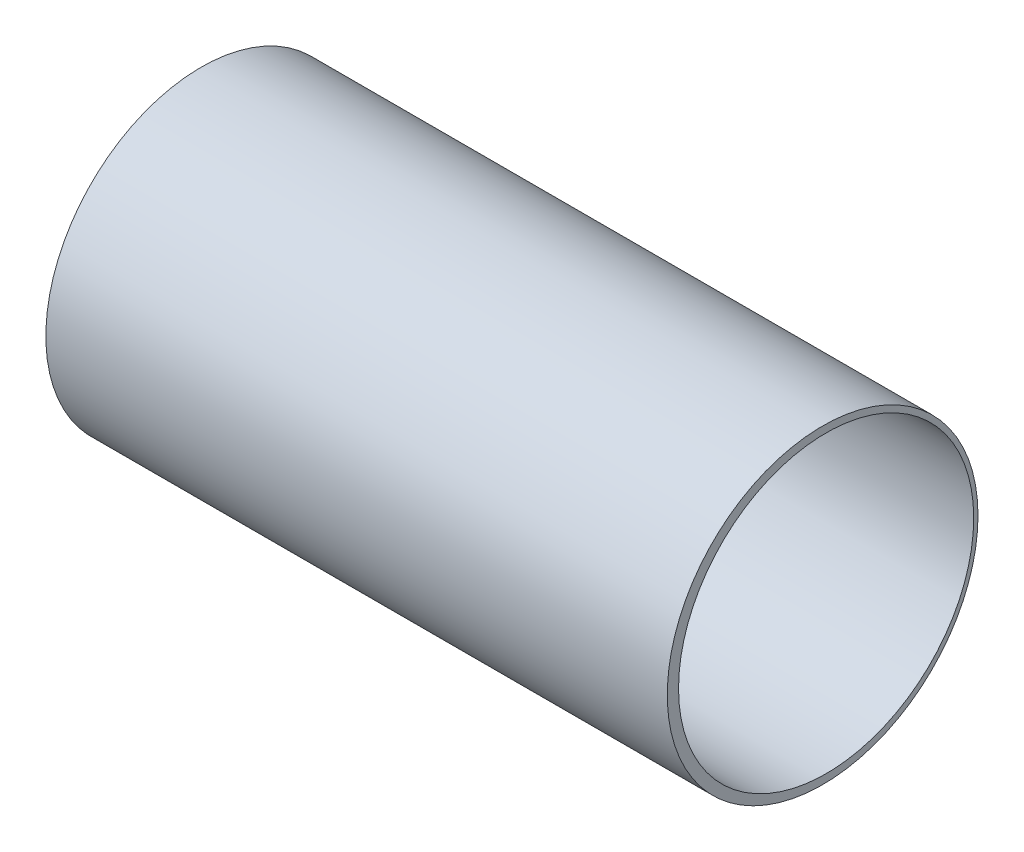
from build123d import *

# Parameters (mm, degrees)
BOSS_EXTRUDE1_DEPTH      = 100
BOSS_EXTRUDE1_DEPTH_BACK = 100
SKETCH1_R                = 50
SKETCH1_R_2              = 47.5


with BuildPart() as part:
    # Sketch1 → Boss-Extrude1 (new, two sides: drawn at the far end of the back side and taken through both)
    with BuildSketch(Plane(origin=(0, 0, 0), x_dir=(0, 0, -1), z_dir=(1, 0, 0)).offset(-BOSS_EXTRUDE1_DEPTH_BACK)):
        Circle(SKETCH1_R)
        with Locations((1.12039307, 0)):
            Circle(SKETCH1_R_2, mode=Mode.SUBTRACT)
    extrude(amount=BOSS_EXTRUDE1_DEPTH + BOSS_EXTRUDE1_DEPTH_BACK)


solid = part.part
